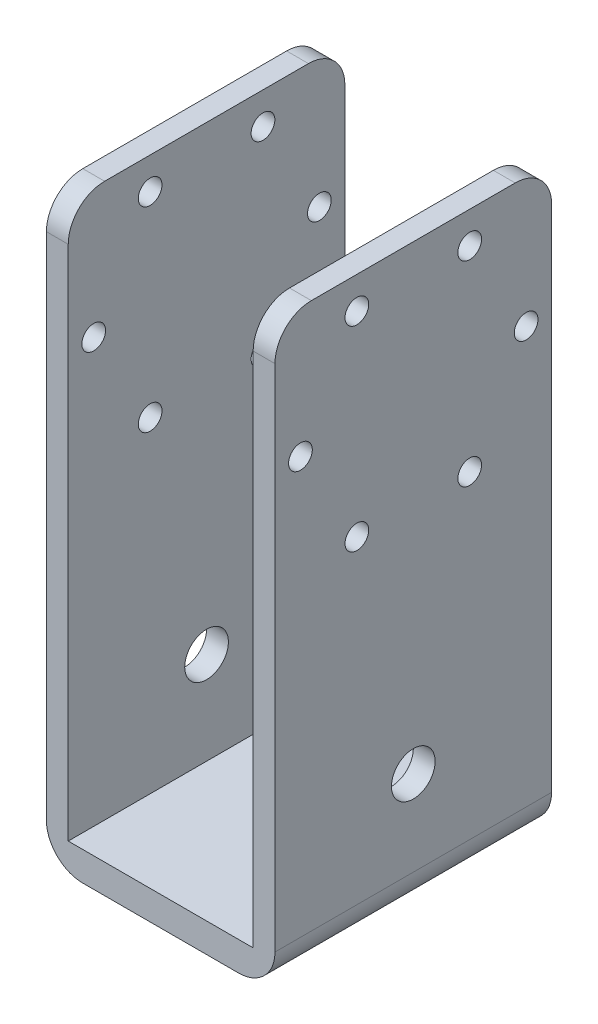
from build123d import *

# Parameters (mm, degrees)
BOSS_EXTRUDE1_DEPTH = 19
SKETCH2_R           = 1.63
CUT_EXTRUDE1_DEPTH  = 32.4
FILLET1_R           = 5
SKETCH4_R           = 3
CUT_EXTRUDE3_DEPTH  = 32.4


with BuildPart() as part:
    # Sketch1 → Boss-Extrude1 (new body, symmetric)
    with BuildSketch(Plane.XY):
        Polygon((-15.7, 80), (-12.7, 80), (-12.7, 4), (12.7, 4), (12.7, 80), (15.7, 80), (15.7, 0), (-15.7, 0), align=None)
    extrude(amount=BOSS_EXTRUDE1_DEPTH, both=True)

    # Sketch2 → Cut-Extrude1 (cut, through all)
    with BuildSketch(Plane(origin=(15.7, 0, 0), x_dir=(0, 0, -1), z_dir=(1, 0, 0))):
        with Locations((-7.75, 75.63)):
            Circle(SKETCH2_R)
        with Locations((7.75, 75.63)):
            Circle(SKETCH2_R)
        with Locations((-15.5, 62.2)):
            Circle(SKETCH2_R)
        with Locations((15.5, 62.2)):
            Circle(SKETCH2_R)
        with Locations((-7.75, 48.77)):
            Circle(SKETCH2_R)
        with Locations((7.75, 48.77)):
            Circle(SKETCH2_R)
    extrude(amount=-CUT_EXTRUDE1_DEPTH, mode=Mode.SUBTRACT)

    # Fillet1
    fillet1_edges = [part.edges().sort_by_distance(p)[0] for p in [
        (14.2, 80, -19),
        (15.7, 0, 0),
        (-15.7, 0, 0),
        (14.2, 80, 19),
        (-14.2, 80, 19),
        (-14.2, 80, -19),
    ]]
    fillet(fillet1_edges, radius=FILLET1_R)

    # Sketch4 → Cut-Extrude3 (cut, through all)
    with BuildSketch(Plane(origin=(15.7, 0, 0), x_dir=(0, 0, -1), z_dir=(1, 0, 0))):
        with Locations((0, 16.7)):
            Circle(SKETCH4_R)
    extrude(amount=-CUT_EXTRUDE3_DEPTH, mode=Mode.SUBTRACT)


solid = part.part
